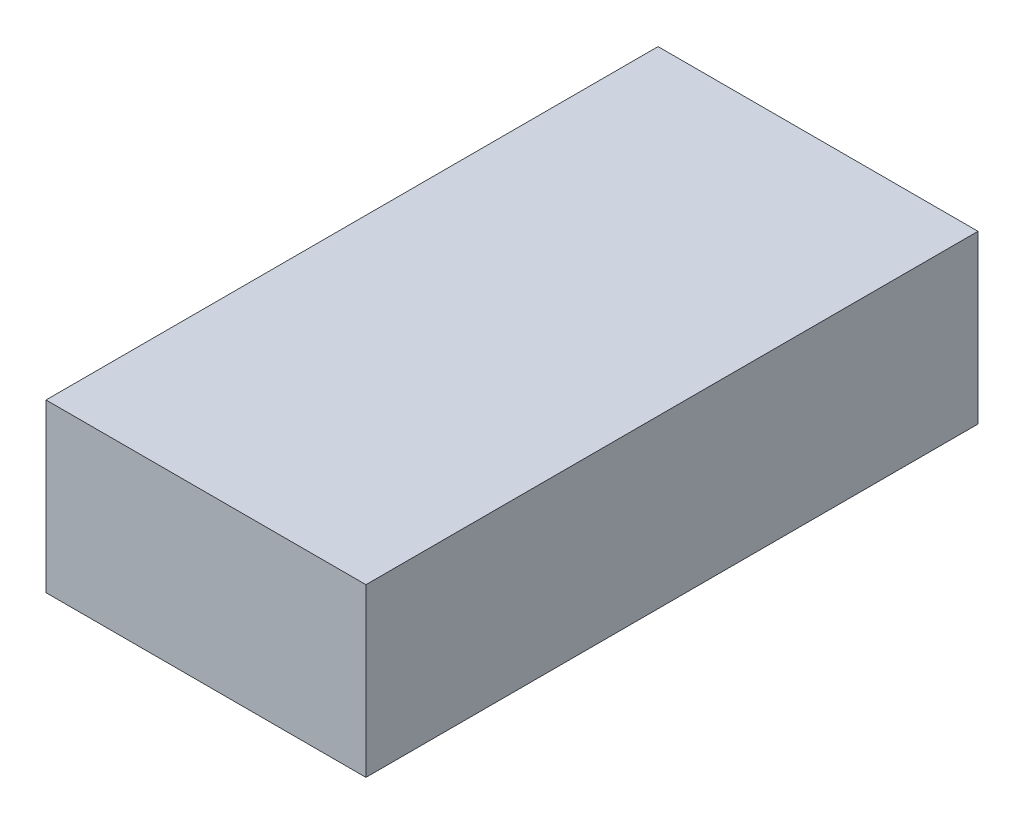
from build123d import *

# Parameters (mm, degrees)
SKETCH1_W           = 73.025
SKETCH1_H           = 139.7
BOSS_EXTRUDE1_DEPTH = 38.1


with BuildPart() as part:
    # Sketch1 → Boss-Extrude1 (new body)
    with BuildSketch(Plane(origin=(0, 0, 0), x_dir=(1, 0, 0), z_dir=(0, 1, 0))):
        with Locations((36.5125, 69.85)):
            Rectangle(SKETCH1_W, SKETCH1_H)
    extrude(amount=BOSS_EXTRUDE1_DEPTH)


solid = part.part
